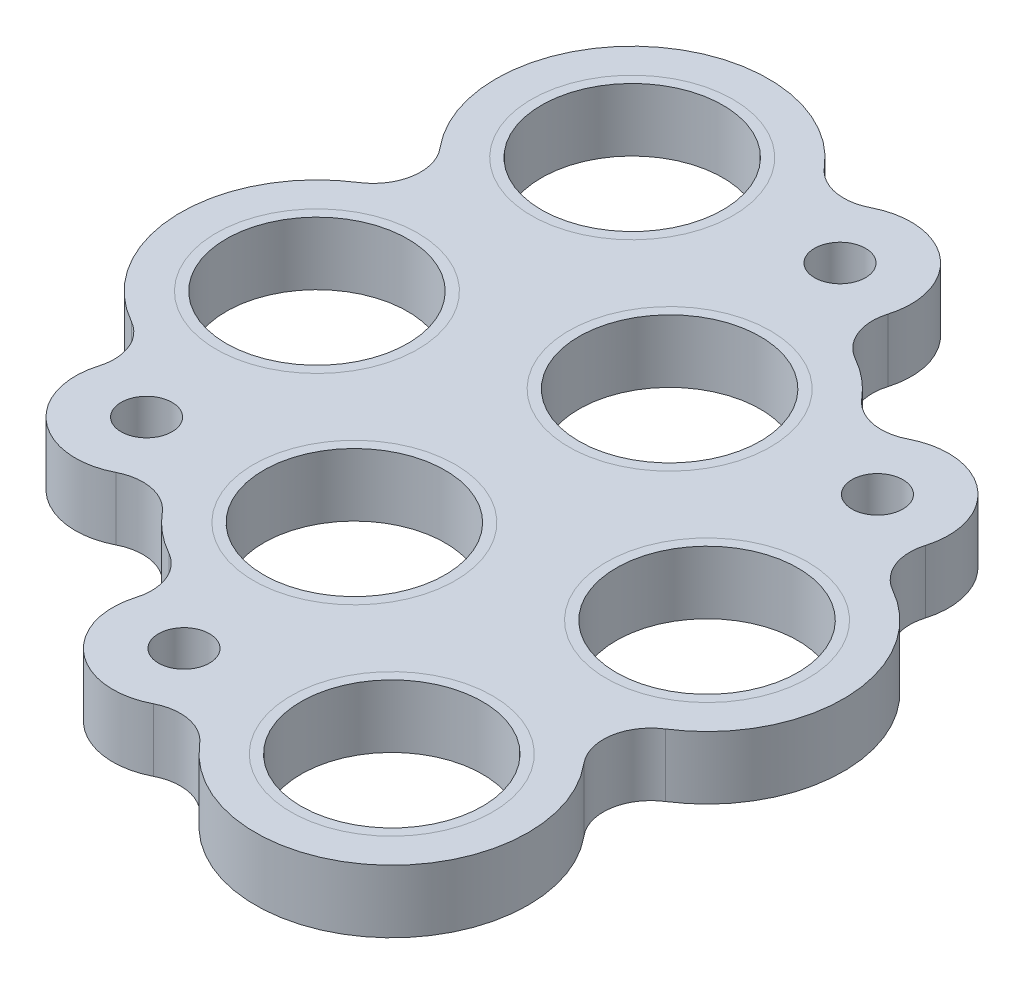
from build123d import *

# Parameters (mm, degrees)
SKETCH3_R           = 7.65
SKETCH3_R_2         = 2.15
BOSS_EXTRUDE1_DEPTH = 5.3


with BuildPart() as part:
    # Sketch3 → Boss-Extrude1 (new body)
    with BuildSketch(Plane(origin=(0, 0, 0), x_dir=(1, 0, 0), z_dir=(0, 1, 0))):
        with BuildLine():
            ThreePointArc((653.944459341, -1220.242432272), (637.731714088, -1218.814624577), (636.327920195, -1235.029466732))
            ThreePointArc((636.327920195, -1235.029466732), (637.221930793, -1238.210887622), (635.417200611, -1240.979216142))
            ThreePointArc((635.417200611, -1240.979216142), (630.100805603, -1251.003580625), (635.975748621, -1260.711154148))
            ThreePointArc((635.975748621, -1260.711154148), (637.727498088, -1262.697402891), (637.854371527, -1265.34272204))
            ThreePointArc((637.854371527, -1265.34272204), (639.774817514, -1271.674124807), (646.352289419, -1272.389412948))
            ThreePointArc((646.352289419, -1272.389412948), (648.975379282, -1272.024433719), (651.251559888, -1273.378247634))
            ThreePointArc((651.251559888, -1273.378247634), (652.730141334, -1274.850178419), (654.450327382, -1276.030747471))
            ThreePointArc((654.450327382, -1276.030747471), (656.202076849, -1278.016996214), (656.328950289, -1280.662315363))
            ThreePointArc((656.328950289, -1280.662315363), (658.249396276, -1286.99371813), (664.826868181, -1287.709006271))
            ThreePointArc((664.826868181, -1287.709006271), (667.449958044, -1287.344027042), (669.726138649, -1288.697840957))
            ThreePointArc((669.726138649, -1288.697840957), (685.938883902, -1290.125648653), (687.342677795, -1273.910806497))
            ThreePointArc((687.342677795, -1273.910806497), (686.448667197, -1270.729385607), (688.253397379, -1267.961057087))
            ThreePointArc((688.253397379, -1267.961057087), (693.569792387, -1257.936692604), (687.694849369, -1248.229119081))
            ThreePointArc((687.694849369, -1248.229119081), (685.943099902, -1246.242870338), (685.816226463, -1243.59755119))
            ThreePointArc((685.816226463, -1243.59755119), (683.895780476, -1237.266148422), (677.318308571, -1236.550860281))
            ThreePointArc((677.318308571, -1236.550860281), (674.695218708, -1236.91583951), (672.419038102, -1235.562025595))
            ThreePointArc((672.419038102, -1235.562025595), (670.940456656, -1234.09009481), (669.220270608, -1232.909525758))
            ThreePointArc((669.220270608, -1232.909525758), (667.468521141, -1230.923277015), (667.341647701, -1228.277957867))
            ThreePointArc((667.341647701, -1228.277957867), (665.421201714, -1221.946555099), (658.843729809, -1221.231266958))
            ThreePointArc((658.843729809, -1221.231266958), (656.220639946, -1221.596246187), (653.944459341, -1220.242432272))
        make_face()
        with Locations((645.125239428, -1227.62290381)):
            Circle(SKETCH3_R, mode=Mode.SUBTRACT)
        with Locations((663.599818189, -1242.942497133)):
            Circle(SKETCH3_R, mode=Mode.SUBTRACT)
        with Locations((682.074396951, -1258.262090456)):
            Circle(SKETCH3_R, mode=Mode.SUBTRACT)
        with Locations((678.545358562, -1281.317369419)):
            Circle(SKETCH3_R, mode=Mode.SUBTRACT)
        with Locations((660.070779801, -1265.997776096)):
            Circle(SKETCH3_R, mode=Mode.SUBTRACT)
        with Locations((641.596201039, -1250.678182773)):
            Circle(SKETCH3_R, mode=Mode.SUBTRACT)
        with Locations((643.604715845, -1267.055480116)):
            Circle(SKETCH3_R_2, mode=Mode.SUBTRACT)
        with Locations((662.079294606, -1282.375073439)):
            Circle(SKETCH3_R_2, mode=Mode.SUBTRACT)
        with Locations((680.065882145, -1241.884793113)):
            Circle(SKETCH3_R_2, mode=Mode.SUBTRACT)
        with Locations((661.591303384, -1226.56519979)):
            Circle(SKETCH3_R_2, mode=Mode.SUBTRACT)
    extrude(amount=BOSS_EXTRUDE1_DEPTH)


solid = part.part
